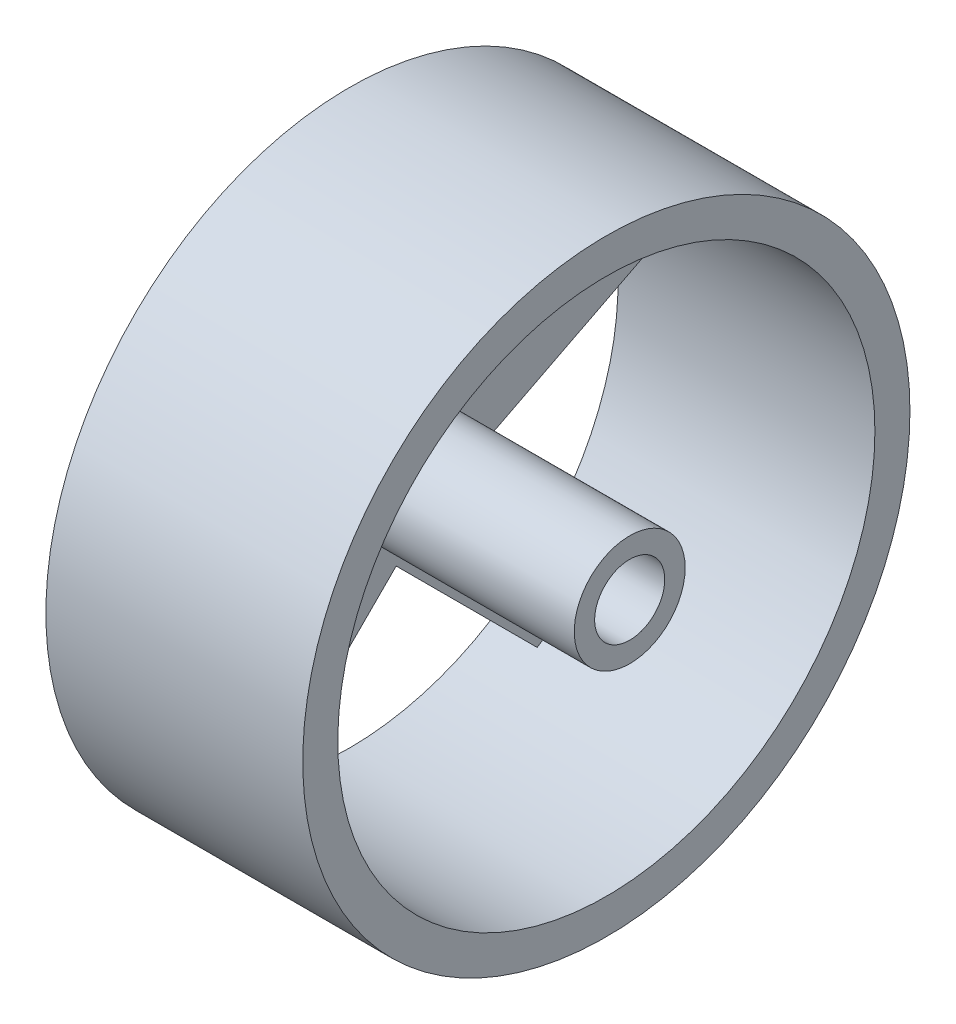
from build123d import *

# Parameters (mm, degrees)
SKETCH_1_R          = 26
EXTRUDE_1_DEPTH     = 4
SKETCH_2_R          = 4.75
EXTRUDE_2_DEPTH     = 20
SKETCH_3_R          = 3
CUT_EXTRUDE_1_DEPTH = 20
SKETCH_4_R          = 26
SKETCH_4_R_2        = 23
EXTRUDE_3_DEPTH     = 18
CUT_EXTRUDE_2_DEPTH = 5
SKETCH_6_R          = 5
CUT_EXTRUDE_3_DEPTH = 2
SKETCH_7_R          = 2.5
EXTRUDE_4_DEPTH     = 3


with BuildPart() as part:
    # 草图1 → 凸台-拉伸1 (new body)
    with BuildSketch(Plane(origin=(0, 0, 0), x_dir=(0, 0, -1), z_dir=(1, 0, 0))):
        Circle(SKETCH_1_R)
    extrude(amount=EXTRUDE_1_DEPTH)

    # 草图2 → 凸台-拉伸2 (add)
    with BuildSketch(Plane(origin=(4, 0, 0), x_dir=(0, 0, -1), z_dir=(1, 0, 0))):
        Circle(SKETCH_2_R)
    extrude(amount=EXTRUDE_2_DEPTH)

    # 草图3 → 切除-拉伸1 (cut)
    with BuildSketch(Plane(origin=(24, 0, 0), x_dir=(0, 0, -1), z_dir=(1, 0, 0))):
        Circle(SKETCH_3_R)
    extrude(amount=-CUT_EXTRUDE_1_DEPTH, mode=Mode.SUBTRACT)

    # 草图4 → 凸台-拉伸3 (add)
    with BuildSketch(Plane(origin=(4, 0, 0), x_dir=(0, 0, -1), z_dir=(1, 0, 0))):
        Circle(SKETCH_4_R)
        Circle(SKETCH_4_R_2, mode=Mode.SUBTRACT)
    extrude(amount=EXTRUDE_3_DEPTH)

    # 草图5 → 切除-拉伸2 (cut, through all)
    with BuildSketch(Plane(origin=(4, 0, 0), x_dir=(0, 0, -1), z_dir=(1, 0, 0))):
        with BuildLine():
            Line((-21.275079931, 8.739048799), (-4.408389392, 6.067627458))
            Line((-4.408389392, 6.067627458), (-1.736968051, 22.934317997))
            ThreePointArc((-1.736968051, 22.934317997), (-13.519060803, 18.607390871), (-21.275079931, 8.739048799))
        make_face()
        with BuildLine():
            Line((21.275079931, 8.739048799), (4.408389392, 6.067627458))
            Line((4.408389392, 6.067627458), (1.736968051, 22.934317997))
            ThreePointArc((1.736968051, 22.934317997), (13.519060803, 18.607390871), (21.275079931, 8.739048799))
        make_face()
        with BuildLine():
            Line((14.885690562, -17.53328881), (7.132923872, -2.317627458))
            Line((7.132923872, -2.317627458), (22.348585224, 5.435139232))
            ThreePointArc((22.348585224, 5.435139232), (21.874299875, -7.107390871), (14.885690562, -17.53328881))
        make_face()
        with BuildLine():
            Line((-12.075217218, -19.575217218), (0, -7.5))
            Line((0, -7.5), (12.075217218, -19.575217218))
            ThreePointArc((12.075217218, -19.575217218), (0, -23), (-12.075217218, -19.575217218))
        make_face()
        with BuildLine():
            Line((-22.348585224, 5.435139232), (-7.132923872, -2.317627458))
            Line((-7.132923872, -2.317627458), (-14.885690562, -17.53328881))
            ThreePointArc((-14.885690562, -17.53328881), (-21.874299875, -7.107390871), (-22.348585224, 5.435139232))
        make_face()
    extrude(amount=-CUT_EXTRUDE_2_DEPTH, mode=Mode.SUBTRACT)

    # 草图6 → 切除-拉伸3 (cut)
    with BuildSketch(Plane.ZY):
        Circle(SKETCH_6_R)
    extrude(amount=-CUT_EXTRUDE_3_DEPTH, mode=Mode.SUBTRACT)

    # 草图7 → 凸台-拉伸4 (add)
    with BuildSketch(Plane.ZY.offset(-2)):
        Circle(SKETCH_7_R)
    extrude(amount=EXTRUDE_4_DEPTH)


solid = part.part
